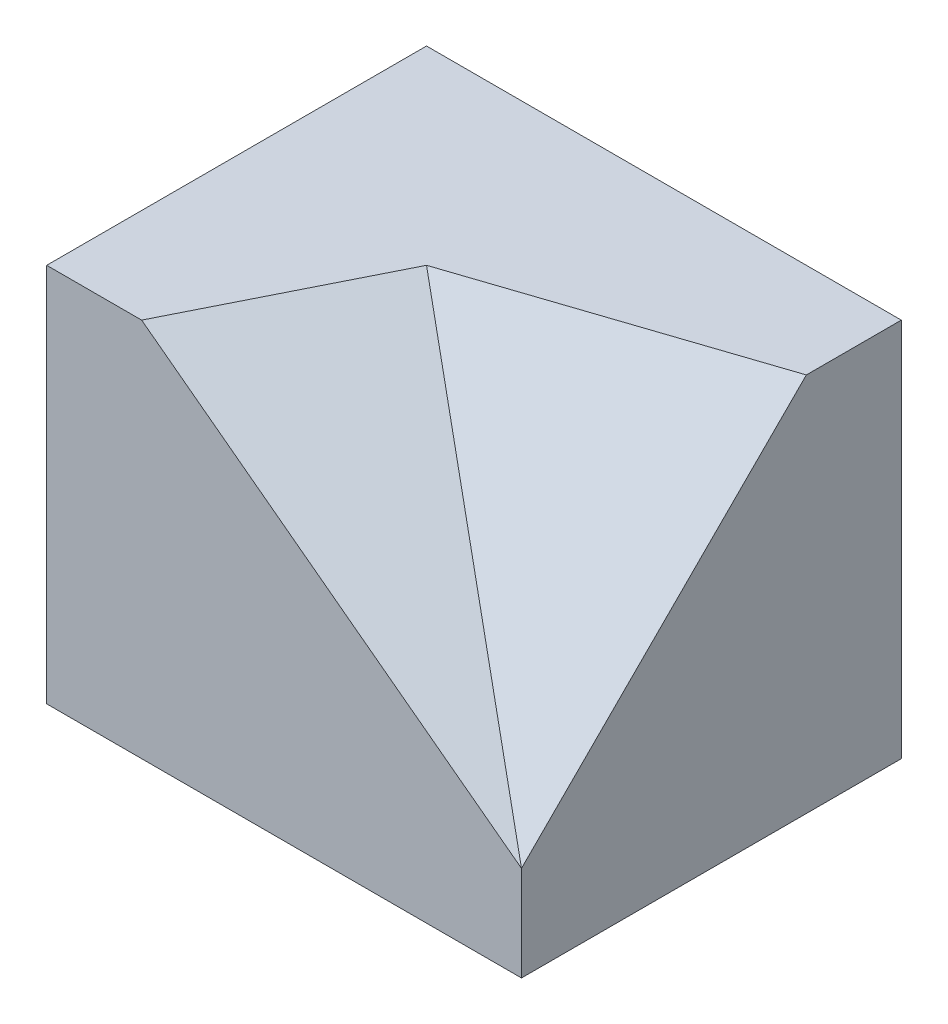
from build123d import *

# Parameters (mm, degrees)
SKETCH_18_W          = 50
SKETCH_18_H          = 40
EXTRUDE_2_DEPTH      = 40
CUT_EXTRUDE_9_DEPTH  = 40
CUT_EXTRUDE_10_DEPTH = 40


with BuildPart() as part:
    # 草圖18 → 填料-伸長2 (new body)
    with BuildSketch(Plane(origin=(0, 0, 0), x_dir=(1, 0, 0), z_dir=(0, 1, 0))):
        Rectangle(SKETCH_18_W, SKETCH_18_H)
    extrude(amount=EXTRUDE_2_DEPTH)

    # 草圖28 → 除料-伸長9 (cut)
    with BuildSketch(Plane(origin=(15.963302752, 21.28440367, 7.981651376), x_dir=(0.818367137, -0.538104419, -0.201789157), z_dir=(0.574695771, 0.766261028, 0.287347886))):
        Polygon((-37.835466942, -4.681645888), (-25.616012434, 14.044937664), (11.042351093, -15.215349135), align=None)
    extrude(amount=CUT_EXTRUDE_9_DEPTH, mode=Mode.SUBTRACT)

    # 草圖31 → 除料-伸長10 (cut)
    with BuildSketch(Plane(origin=(6.052631579, 18.157894737, 18.157894737), x_dir=(-0.973328527, 0.162221421, 0.162221421), z_dir=(-0.229415734, -0.688247202, -0.688247202))):
        Polygon((11.355499479, 28.284271247), (-19.466570536, 35.355339059), (-19.466570536, -7.071067812), align=None)
    extrude(amount=-CUT_EXTRUDE_10_DEPTH, mode=Mode.SUBTRACT)


solid = part.part
